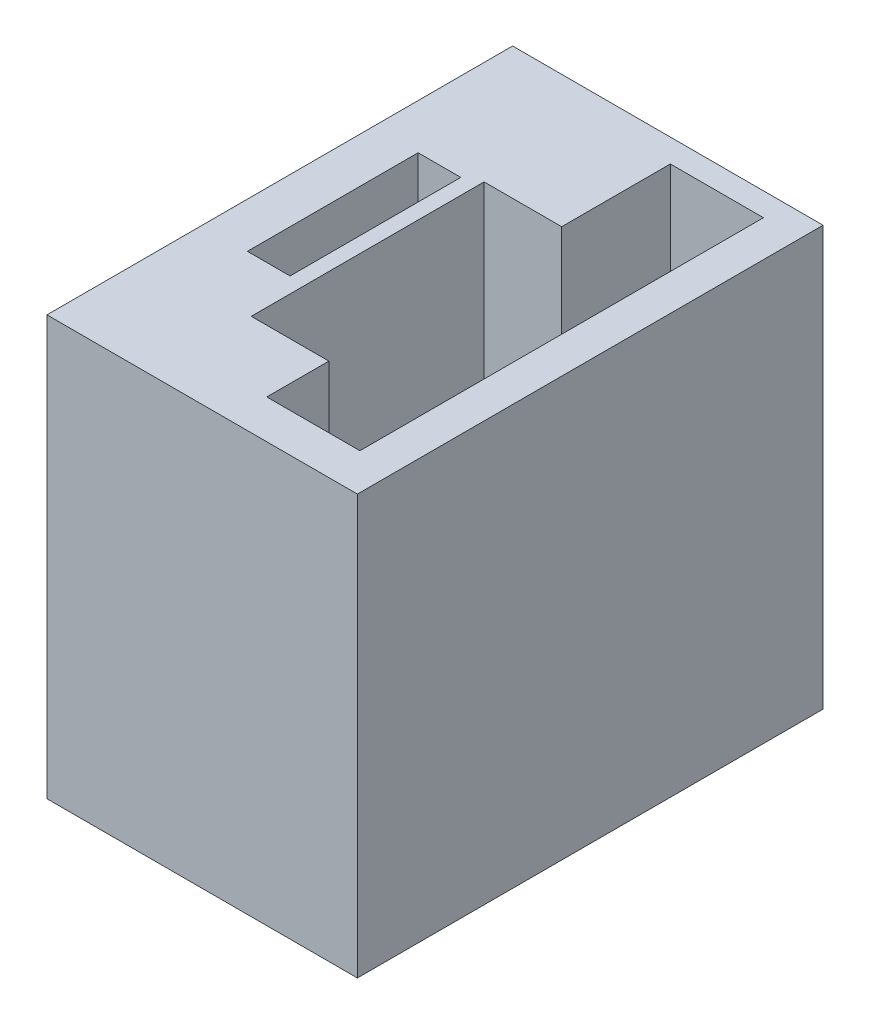
from build123d import *

# Parameters (mm, degrees)
SKETCH2_W           = 30
SKETCH2_H           = 27
BOSS_EXTRUDE1_DEPTH = 20
SKETCH6_W           = 6
SKETCH6_H           = 26
CUT_EXTRUDE4_DEPTH  = 26
SKETCH9_W           = 5
SKETCH9_H           = 15
CUT_EXTRUDE5_DEPTH  = 21
SKETCH11_R          = 5
CUT_EXTRUDE8_DEPTH  = 0.5
SKETCH12_W          = 2.75
SKETCH12_H          = 11
CUT_EXTRUDE12_DEPTH = 17.5
SKETCH15_R          = 4.5
CUT_EXTRUDE13_DEPTH = 6


with BuildPart() as part:
    # Sketch2 → Boss-Extrude1 (new body)
    with BuildSketch(Plane(origin=(0, 0, 0), x_dir=(0, 0, -1), z_dir=(1, 0, 0))):
        with Locations((15, 13.5)):
            Rectangle(SKETCH2_W, SKETCH2_H)
    extrude(amount=BOSS_EXTRUDE1_DEPTH)

    # Sketch6 → Cut-Extrude4 (cut)
    with BuildSketch(Plane(origin=(2.296116437, 27, -0.293484995), x_dir=(1, 0, 0), z_dir=(0, 1, 0))):
        with Locations((12.365844825, 15.206515005)):
            Rectangle(SKETCH6_W, SKETCH6_H)
    extrude(amount=-CUT_EXTRUDE4_DEPTH, mode=Mode.SUBTRACT)

    # Sketch9 → Cut-Extrude5 (cut)
    with BuildSketch(Plane(origin=(0, 27, 0), x_dir=(1, 0, 0), z_dir=(0, 1, 0))):
        with Locations((9.161961261, 14)):
            Rectangle(SKETCH9_W, SKETCH9_H)
    extrude(amount=-CUT_EXTRUDE5_DEPTH, mode=Mode.SUBTRACT)

    # Sketch11 → Cut-Extrude8 (cut)
    with BuildSketch(Plane.ZY):
        with Locations((-15.1, 13.5)):
            Circle(SKETCH11_R)
    extrude(amount=-CUT_EXTRUDE8_DEPTH, mode=Mode.SUBTRACT)

    # Sketch12 → Cut-Extrude12 (cut)
    with BuildSketch(Plane(origin=(0, 27, 0), x_dir=(1, 0, 0), z_dir=(0, 1, 0))):
        with Locations((4.286961261, 15.5)):
            Rectangle(SKETCH12_W, SKETCH12_H)
    extrude(amount=-CUT_EXTRUDE12_DEPTH, mode=Mode.SUBTRACT)

    # Sketch15 → Cut-Extrude13 (cut)
    with BuildSketch(Plane.ZY.offset(-0.5)):
        with Locations((-15.04, 13.5)):
            Circle(SKETCH15_R)
    extrude(amount=-CUT_EXTRUDE13_DEPTH, mode=Mode.SUBTRACT)


solid = part.part
